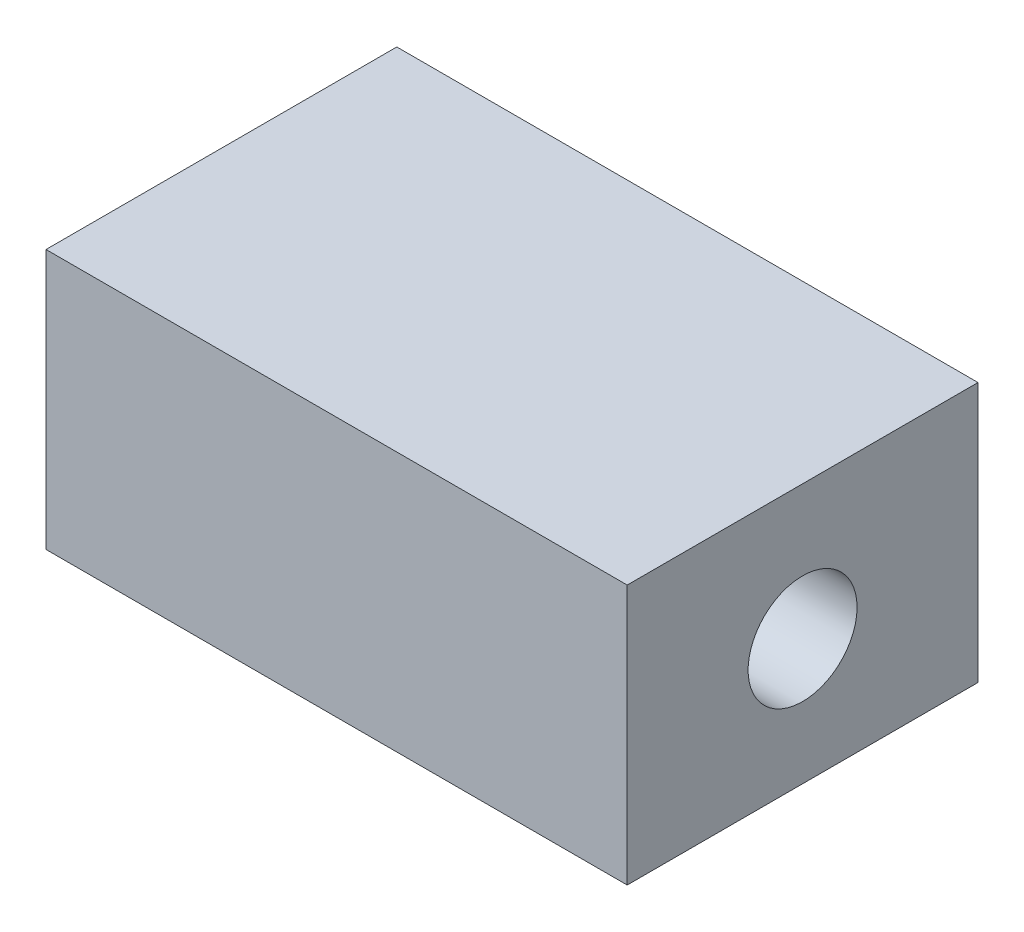
from build123d import *

# Parameters (mm, degrees)
SKETCH1_W           = 111.851353708
SKETCH1_H           = 67.507917622
BOSS_EXTRUDE1_DEPTH = 50
SKETCH2_R           = 10.481364908
CUT_EXTRUDE1_DEPTH  = 112.851353707


with BuildPart() as part:
    # Sketch1 → Boss-Extrude1 (new body)
    with BuildSketch(Plane(origin=(0, 0, 0), x_dir=(1, 0, 0), z_dir=(0, 1, 0))):
        Rectangle(SKETCH1_W, SKETCH1_H)
    extrude(amount=BOSS_EXTRUDE1_DEPTH)

    # Sketch2 → Cut-Extrude1 (cut, through all)
    with BuildSketch(Plane(origin=(55.925676854, 0, 0), x_dir=(0, 0, -1), z_dir=(1, 0, 0))):
        with Locations((0, 24.182587741)):
            Circle(SKETCH2_R)
    extrude(amount=-CUT_EXTRUDE1_DEPTH, mode=Mode.SUBTRACT)


solid = part.part
